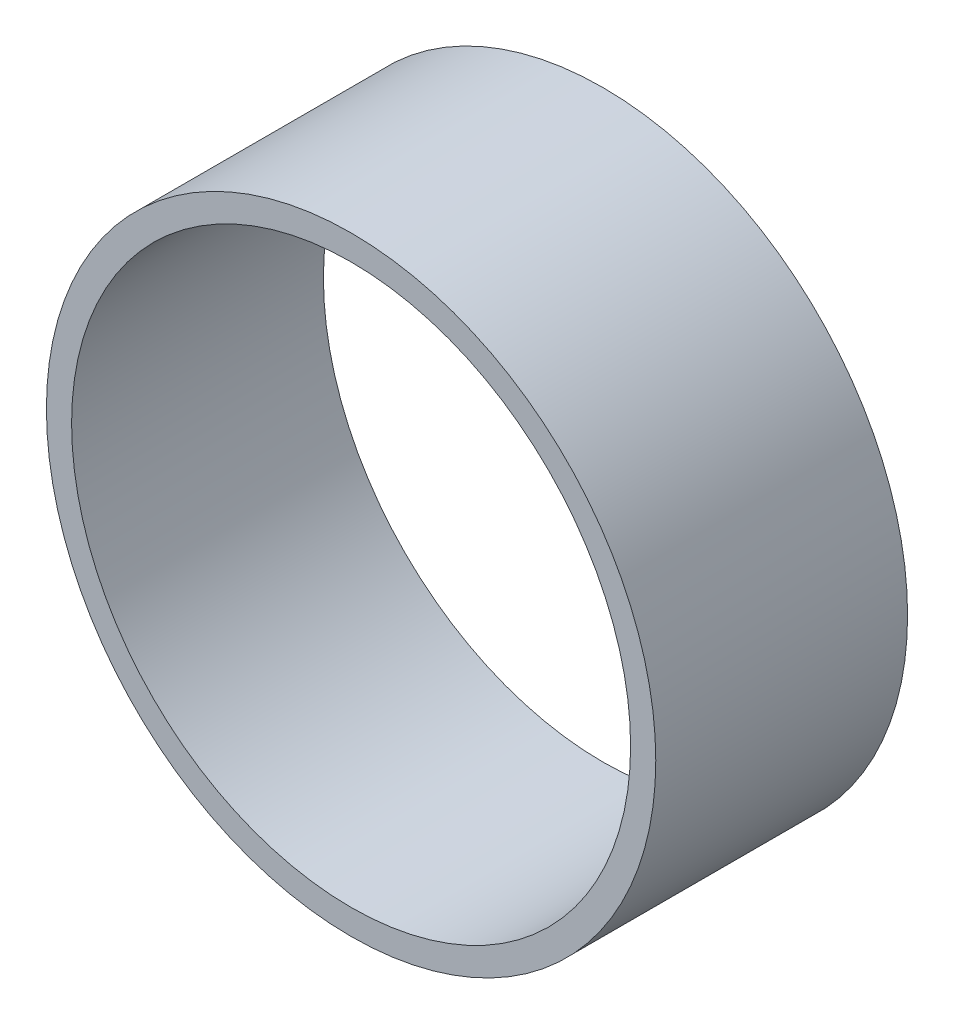
from build123d import *

# Parameters (mm, degrees)
SKETCH1_R           = 12.1
SKETCH1_R_2         = 11.1
BOSS_EXTRUDE1_DEPTH = 10


with BuildPart() as part:
    # Sketch1 → Boss-Extrude1 (new body)
    with BuildSketch(Plane.XY):
        Circle(SKETCH1_R)
        Circle(SKETCH1_R_2, mode=Mode.SUBTRACT)
    extrude(amount=BOSS_EXTRUDE1_DEPTH)


solid = part.part
